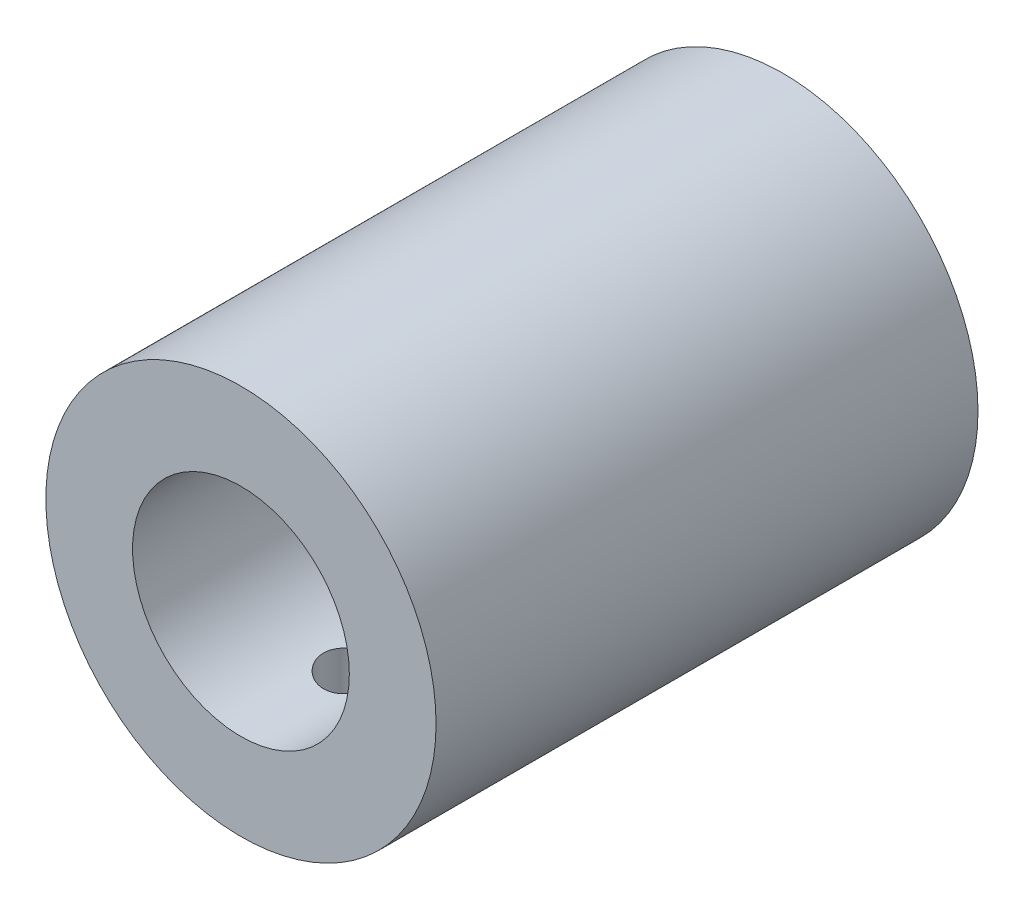
from build123d import *

# Parameters (mm, degrees)
SKETCH1_R           = 9
SKETCH1_R_2         = 3
BOSS_EXTRUDE1_DEPTH = 25
SKETCH2_R           = 5
CUT_EXTRUDE1_DEPTH  = 12.446
SKETCH3_R           = 1.27
CUT_EXTRUDE2_DEPTH  = 12.446


with BuildPart() as part:
    # Sketch1 → Boss-Extrude1 (new body)
    with BuildSketch(Plane.XY):
        Circle(SKETCH1_R)
        Circle(SKETCH1_R_2, mode=Mode.SUBTRACT)
    extrude(amount=BOSS_EXTRUDE1_DEPTH)

    # Sketch2 → Cut-Extrude1 (cut)
    with BuildSketch(Plane.XY.offset(25)):
        Circle(SKETCH2_R)
    extrude(amount=-CUT_EXTRUDE1_DEPTH, mode=Mode.SUBTRACT)

    # Sketch3 → Cut-Extrude2 (cut)
    with BuildSketch(Plane(origin=(0, 0, 0), x_dir=(1, 0, 0), z_dir=(0, 1, 0))):
        with Locations((0, -5.08)):
            Circle(SKETCH3_R)
        with Locations((0, -19.92)):
            Circle(SKETCH3_R)
    extrude(amount=-CUT_EXTRUDE2_DEPTH, mode=Mode.SUBTRACT)


solid = part.part
